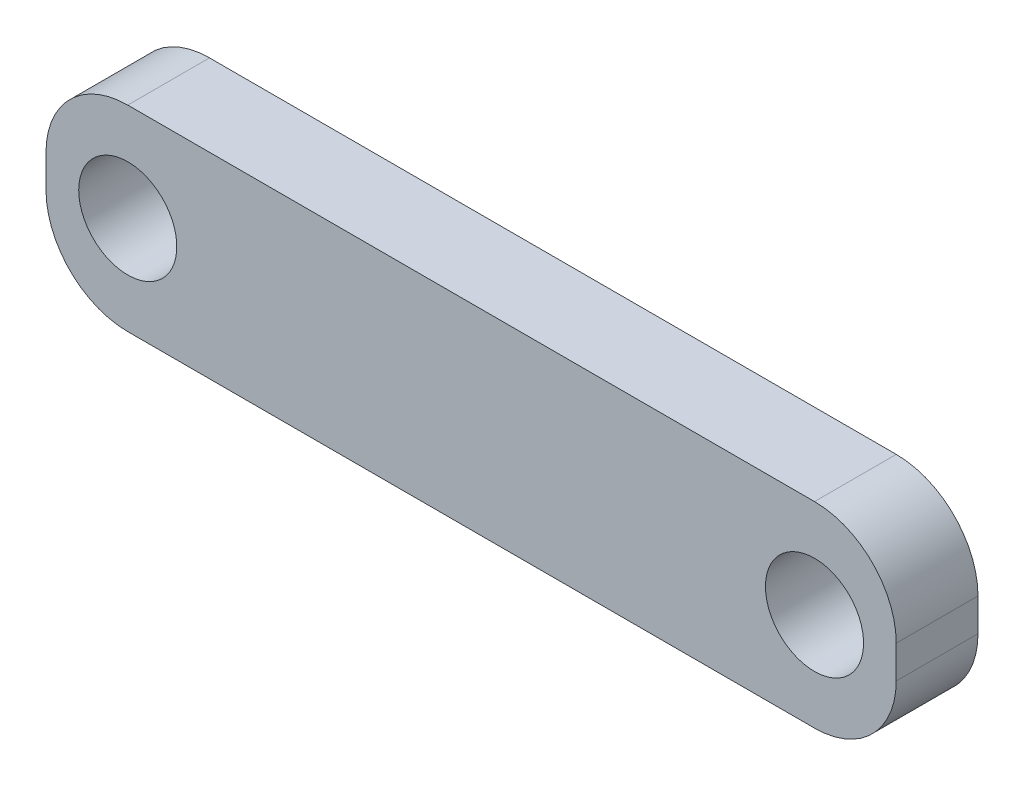
from build123d import *

# Parameters (mm, degrees)
ESQUISSE1_R        = 3
BOSS_EXTRU_1_DEPTH = 5


with BuildPart() as part:
    # Esquisse1 → Boss.-Extru.1 (new body)
    with BuildSketch(Plane.XY.offset(5)):
        with BuildLine():
            Line((-26, 1), (-26, -1))
            ThreePointArc((-26, -1), (-24.535533906, -4.535533906), (-21, -6))
            Line((-21, -6), (21, -6))
            ThreePointArc((21, -6), (24.535533906, -4.535533906), (26, -1))
            Line((26, -1), (26, 1))
            ThreePointArc((26, 1), (24.535533906, 4.535533906), (21, 6))
            Line((21, 6), (-21, 6))
            ThreePointArc((-21, 6), (-24.535533906, 4.535533906), (-26, 1))
        make_face()
        with Locations(Location((21, 0, 0), (0, 0, 180))):  # turned: the seam where the file's is
            Circle(ESQUISSE1_R, mode=Mode.SUBTRACT)
        with Locations(Location((-21, 0, 0), (0, 0, 180))):  # turned: the seam where the file's is
            Circle(ESQUISSE1_R, mode=Mode.SUBTRACT)
    extrude(amount=-BOSS_EXTRU_1_DEPTH)


solid = part.part
